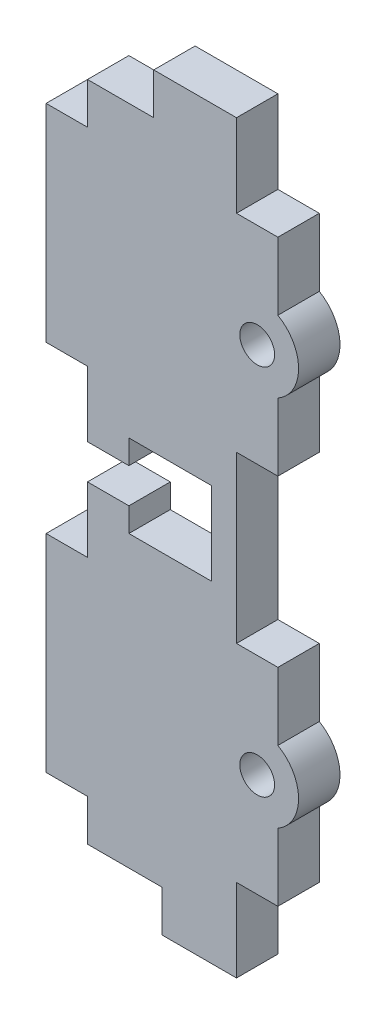
from build123d import *

# Parameters (mm, degrees)
SKETCH1_W           = 18
SKETCH1_H           = 80
BOSS_EXTRUDE1_DEPTH = 5
SKETCH2_W           = 5
SKETCH2_H           = 25
BOSS_EXTRUDE2_DEPTH = 5
SKETCH3_W           = 9
SKETCH3_H           = 5
BOSS_EXTRUDE3_DEPTH = 5
SKETCH4_W           = 10
SKETCH4_H           = 5
BOSS_EXTRUDE4_DEPTH = 5
SKETCH5_R           = 2.1
CUT_EXTRUDE1_DEPTH  = 5
BOSS_EXTRUDE5_DEPTH = 5
SKETCH7_W           = 5
SKETCH7_H           = 4.2
CUT_EXTRUDE2_DEPTH  = 5


with BuildPart() as part:
    # Sketch1 → Boss-Extrude1 (new body)
    with BuildSketch(Plane.XY):
        with Locations((-9, 40)):
            Rectangle(SKETCH1_W, SKETCH1_H)
    extrude(amount=BOSS_EXTRUDE1_DEPTH)

    # Sketch2 → Boss-Extrude2 (add)
    with BuildSketch(Plane(origin=(0, 0, 0), x_dir=(-1, 0, 0), z_dir=(0, 0, -1))):
        with Locations((-2.5, 62.5)):
            Rectangle(SKETCH2_W, SKETCH2_H)
        with Locations((-2.5, 17.5)):
            Rectangle(SKETCH2_W, SKETCH2_H)
        with Locations((20.5, 17.5)):
            Rectangle(SKETCH2_W, SKETCH2_H)
        with Locations((20.5, 62.5)):
            Rectangle(SKETCH2_W, SKETCH2_H)
    extrude(amount=-BOSS_EXTRUDE2_DEPTH)

    # Sketch3 → Boss-Extrude3 (add)
    with BuildSketch(Plane.XZ):
        with Locations((-4.5, 2.5)):
            Rectangle(SKETCH3_W, SKETCH3_H)
    extrude(amount=BOSS_EXTRUDE3_DEPTH)

    # Sketch4 → Boss-Extrude4 (add)
    with BuildSketch(Plane(origin=(0, 0, 0), x_dir=(-1, 0, 0), z_dir=(0, 0, -1))):
        with Locations((5, 82.5)):
            Rectangle(SKETCH4_W, SKETCH4_H)
    extrude(amount=-BOSS_EXTRUDE4_DEPTH)

    # Sketch5 → Cut-Extrude1 (cut)
    with BuildSketch(Plane(origin=(0, 0, 0), x_dir=(-1, 0, 0), z_dir=(0, 0, -1))):
        with Locations((-2.5, 62.5)):
            Circle(SKETCH5_R)
        with Locations((-2.5, 17.5)):
            Circle(SKETCH5_R)
    extrude(amount=-CUT_EXTRUDE1_DEPTH, mode=Mode.SUBTRACT)

    # Sketch6 → Boss-Extrude5 (add)
    with BuildSketch(Plane(origin=(0, 0, 0), x_dir=(-1, 0, 0), z_dir=(0, 0, -1))):
        with BuildLine():
            Line((-5, 66.830127019), (-5, 58.169872981))
            ThreePointArc((-5, 58.169872981), (-7.5, 62.5), (-5, 66.830127019))
        make_face()
        with BuildLine():
            Line((-5, 13.169872981), (-5, 21.830127019))
            ThreePointArc((-5, 21.830127019), (-7.5, 17.5), (-5, 13.169872981))
        make_face()
    extrude(amount=-BOSS_EXTRUDE5_DEPTH)

    # Sketch7 → Cut-Extrude2 (cut)
    with BuildSketch(Plane.XY.offset(5)):
        Polygon((-13, 45), (-13, 42.1), (-13, 37.9), (-13, 35), (-3, 35), (-3, 45), align=None)
        with Locations((-15.5, 40)):
            Rectangle(SKETCH7_W, SKETCH7_H)
    extrude(amount=-CUT_EXTRUDE2_DEPTH, mode=Mode.SUBTRACT)


solid = part.part
